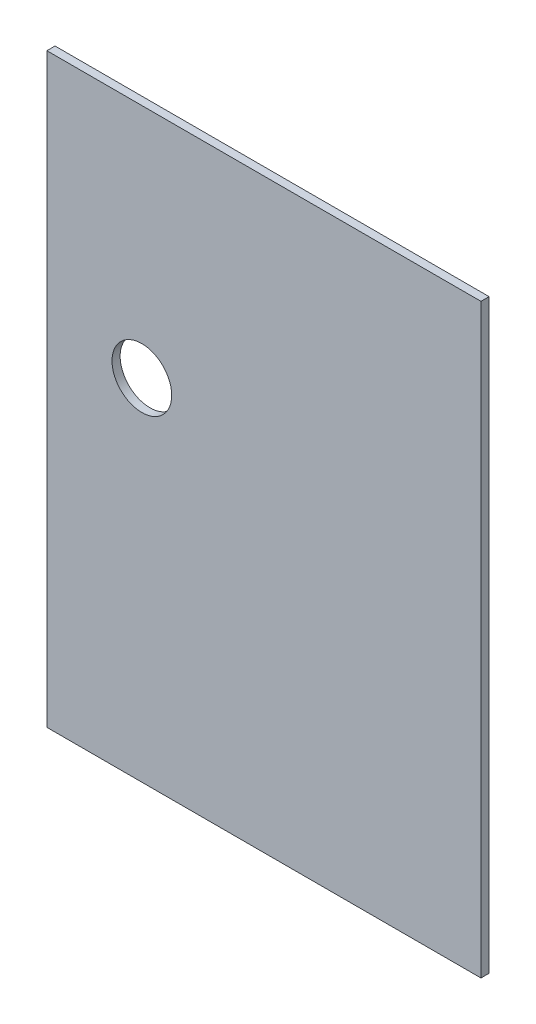
from build123d import *

# Parameters (mm, degrees)
SKETCH1_W           = 160
SKETCH1_H           = 216
BOSS_EXTRUDE1_DEPTH = 3
SKETCH2_R           = 11
CUT_EXTRUDE1_DEPTH  = 3


with BuildPart() as part:
    # Sketch1 → Boss-Extrude1 (new body)
    with BuildSketch(Plane.XY):
        with Locations((80, 108)):
            Rectangle(SKETCH1_W, SKETCH1_H)
    extrude(amount=BOSS_EXTRUDE1_DEPTH)

    # Sketch2 → Cut-Extrude1 (cut)
    with BuildSketch(Plane.XY.offset(3)):
        with Locations((35, 129)):
            Circle(SKETCH2_R)
    extrude(amount=-CUT_EXTRUDE1_DEPTH, mode=Mode.SUBTRACT)


solid = part.part
